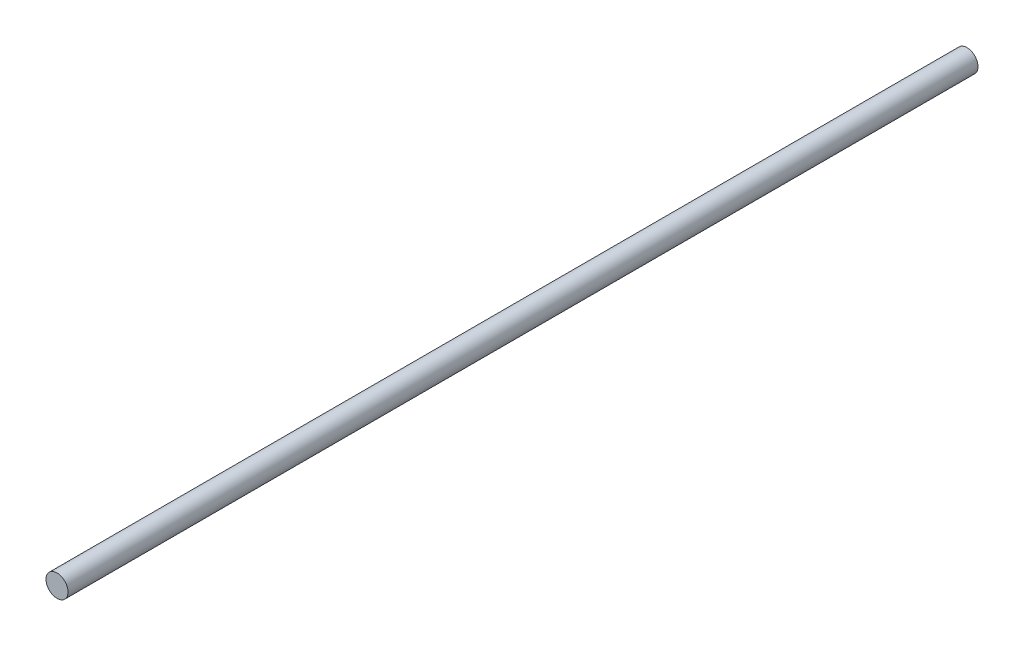
from build123d import *

# Parameters (mm, degrees)
SKETCH1_R           = 4
BOSS_EXTRUDE1_DEPTH = 165


with BuildPart() as part:
    # Sketch1 → Boss-Extrude1 (new body, symmetric)
    with BuildSketch(Plane.XY):
        Circle(SKETCH1_R)
    extrude(amount=BOSS_EXTRUDE1_DEPTH, both=True)


solid = part.part
